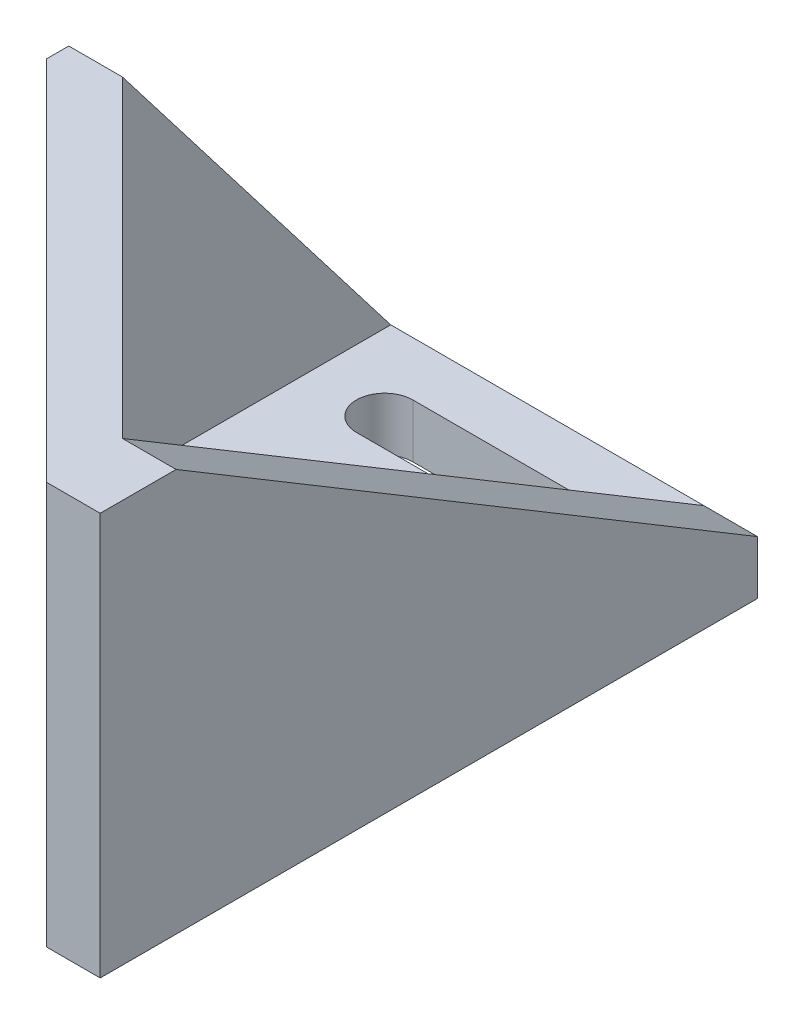
from build123d import *

# Parameters (mm, degrees)
SALIENTE_EXTRUIR1_DEPTH = 4
SALIENTE_EXTRUIR2_DEPTH = 30
SALIENTE_EXTRUIR5_DEPTH = 4
SALIENTE_EXTRUIR7_DEPTH = 4
CORTAR_EXTRUIR2_DEPTH   = 31
CROQUIS13_R             = 2.05
CORTAR_EXTRUIR3_DEPTH   = 4
CORTAR_EXTRUIR4_DEPTH   = 5
CORTAR_EXTRUIR5_DEPTH   = 2


with BuildPart() as part:
    # Croquis1 → Saliente-Extruir1 (new body)
    with BuildSketch(Plane(origin=(0, 0, 0), x_dir=(1, 0, 0), z_dir=(0, 1, 0))):
        Polygon((-11.66726189, 1.66726189), (11.66726189, -21.66726189), (11.66726189, 21.66726189), (-11.66726189, 21.66726189), align=None)
    extrude(amount=SALIENTE_EXTRUIR1_DEPTH)

    # Croquis3 → Saliente-Extruir2 (add)
    with BuildSketch(Plane.XZ):
        Polygon((-11.66726189, -1.66726189), (-11.66726189, 3.98959236), (11.66726189, 27.324116139), (11.66726189, 21.66726189), align=None)
    extrude(amount=-SALIENTE_EXTRUIR2_DEPTH)

    # Croquis7 → Saliente-Extruir5 (add)
    with BuildSketch(Plane(origin=(11.66726189, 0, 0), x_dir=(0, 0, -1), z_dir=(1, 0, 0))):
        Polygon((-21.66726189, 30), (21.66726189, 4), (21.66726189, 0), (-27.324116139, 0), (-27.324116139, 30), align=None)
    extrude(amount=SALIENTE_EXTRUIR5_DEPTH)

    # Croquis10 → Saliente-Extruir7 (add)
    with BuildSketch(Plane.ZY.offset(11.66726189)):
        Polygon((-1.66726189, 30), (-21.66726189, 4), (-21.66726189, 0), (3.98959236, 0), (3.98959236, 30), align=None)
    extrude(amount=SALIENTE_EXTRUIR7_DEPTH)

    # Croquis11 → Cortar-Extruir2 (cut, through all)
    with BuildSketch(Plane(origin=(0, 30, 0), x_dir=(1, 0, 0), z_dir=(0, 1, 0))):
        Polygon((-11.66726189, -3.98959236), (-15.66726189, 0.01040764), (-15.66726189, -3.98959236), align=None)
    extrude(amount=-CORTAR_EXTRUIR2_DEPTH, mode=Mode.SUBTRACT)

    # Croquis13 → Cortar-Extruir3 (cut)
    with BuildSketch(Plane(origin=(-7.828427125, 0, 7.828427125), x_dir=(0.707106781, 0, 0.707106781), z_dir=(-0.707106781, 0, 0.707106781))):
        with Locations((-3.428932188, 15.375)):
            Circle(CROQUIS13_R)
        with Locations((17.571067812, 15.375)):
            Circle(CROQUIS13_R)
    extrude(amount=-CORTAR_EXTRUIR3_DEPTH, mode=Mode.SUBTRACT)

    # Croquis14 → Cortar-Extruir4 (cut, through all)
    with BuildSketch(Plane(origin=(0, 4, 0), x_dir=(1, 0, 0), z_dir=(0, 1, 0))):
        with BuildLine():
            Line((-6, 17.644253814), (6, 17.644253814))
            ThreePointArc((6, 17.644253814), (8.1, 15.544253814), (6, 13.444253814))
            Line((6, 13.444253814), (-6, 13.444253814))
            ThreePointArc((-6, 13.444253814), (-8.1, 15.544253814), (-6, 17.644253814))
        make_face()
        with BuildLine():
            Line((-6, 7.644253814), (6, 7.644253814))
            ThreePointArc((6, 7.644253814), (8.1, 5.544253814), (6, 3.444253814))
            Line((6, 3.444253814), (-6, 3.444253814))
            ThreePointArc((-6, 3.444253814), (-8.1, 5.544253814), (-6, 7.644253814))
        make_face()
    extrude(amount=-CORTAR_EXTRUIR4_DEPTH, mode=Mode.SUBTRACT)

    # Croquis15 → Cortar-Extruir5 (cut)
    with BuildSketch(Plane(origin=(-5, 0, 5), x_dir=(-0.707106781, 0, -0.707106781), z_dir=(0.707106781, 0, -0.707106781))):
        Polygon((-13.587350954, 15.375), (-15.579209383, 18.825), (-19.562926241, 18.825), (-21.554784669, 15.375), (-19.562926241, 11.925), (-15.579209383, 11.925), align=None)
        Polygon((-0.554784669, 15.375), (1.437073759, 11.925), (5.420790617, 11.925), (7.412649046, 15.375), (5.420790617, 18.825), (1.437073759, 18.825), align=None)
    extrude(amount=-CORTAR_EXTRUIR5_DEPTH, mode=Mode.SUBTRACT)


solid = part.part
